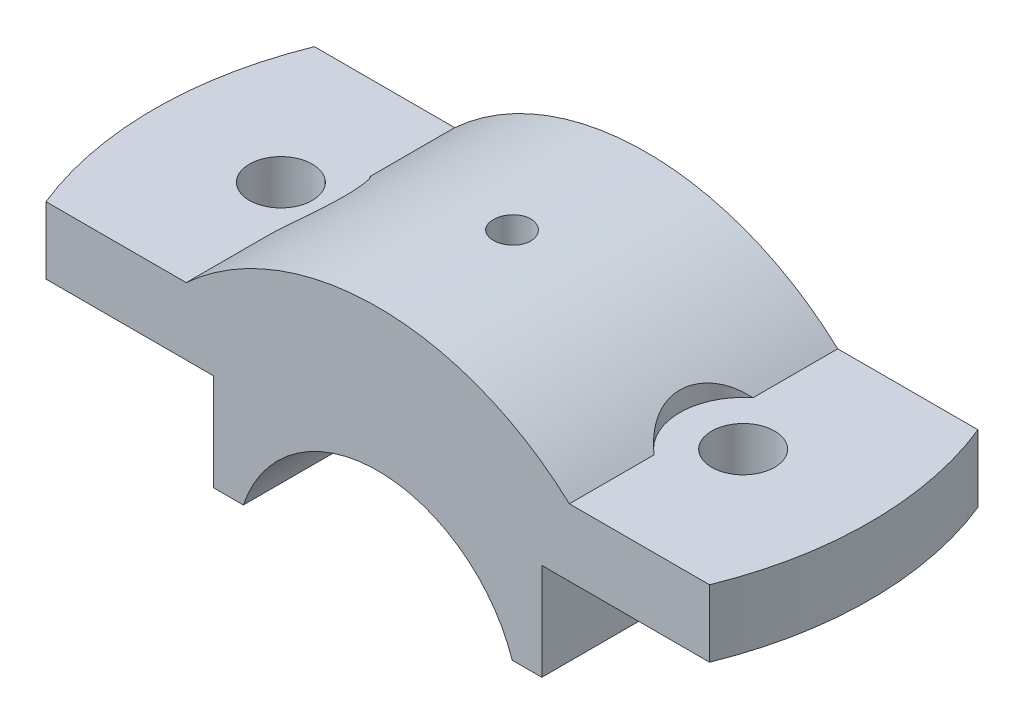
from build123d import *

# Parameters (mm, degrees)
BOSS_EXTRUDE1_DEPTH            = 18
CUT_EXTRUDE1_REACH             = 24
SKETCH2_R                      = 4.221723053
CUT_EXTRUDE1_DIRECTION_2_DEPTH = 11
SKETCH3_R                      = 8.5
CUT_EXTRUDE2_DEPTH             = 36
SKETCH18_W                     = 2.5
SKETCH18_H                     = 13
M5_TAPPED_HOLE1_D              = 4.2


with BuildPart() as part:
    # Sketch1 → Boss-Extrude1 (new body, symmetric)
    with BuildSketch(Plane.XY):
        with BuildLine():
            Line((18.027756377, 6), (22, 6))
            Line((22, 6), (22, 19))
            Line((22, 19), (49, 19))
            Line((49, 19), (49, 28))
            Line((49, 28), (25.690465157, 28))
            ThreePointArc((25.690465157, 28), (0, 38), (-25.690465157, 28))
            Line((-25.690465157, 28), (-49, 28))
            Line((-49, 28), (-49, 19))
            Line((-49, 19), (-22, 19))
            Line((-22, 19), (-22, 6))
            Line((-22, 6), (-18.027756377, 6))
            ThreePointArc((-18.027756377, 6), (0, 19), (18.027756377, 6))
        make_face()
    extrude(amount=BOSS_EXTRUDE1_DEPTH, both=True)

    # Sketch2 → Cut-Extrude1 (cut, up to next)
    with BuildSketch(Plane(origin=(0, 28, 0), x_dir=(1, 0, 0), z_dir=(0, 1, 0)), mode=Mode.PRIVATE) as cut_extrude1_sk1:
        with Locations((-31, 0)):
            Circle(SKETCH2_R)
    cut_extrude1_tool1 = extrude(cut_extrude1_sk1.sketch, amount=-CUT_EXTRUDE1_REACH, mode=Mode.PRIVATE) & part.part
    add(cut_extrude1_tool1.solids().sort_by_distance((-31, 28, 0))[0], mode=Mode.SUBTRACT)
    # Sketch2 → Cut-Extrude1 (cut, up to next)
    with BuildSketch(Plane(origin=(0, 28, 0), x_dir=(1, 0, 0), z_dir=(0, 1, 0)), mode=Mode.PRIVATE) as cut_extrude1_sk2:
        with Locations((31, 0)):
            Circle(SKETCH2_R)
    cut_extrude1_tool2 = extrude(cut_extrude1_sk2.sketch, amount=-CUT_EXTRUDE1_REACH, mode=Mode.PRIVATE) & part.part
    add(cut_extrude1_tool2.solids().sort_by_distance((31, 28, 0))[0], mode=Mode.SUBTRACT)
    # Sketch2 → Cut-Extrude1 (cut, up to next)
    with BuildSketch(Plane(origin=(0, 28, 0), x_dir=(1, 0, 0), z_dir=(0, 1, 0)), mode=Mode.PRIVATE) as cut_extrude1_sk3:
        with BuildLine():
            Line((-44.497190923, 18), (-49, 18))
            Line((-49, 18), (-49, -18))
            Line((-49, -18), (-44.497190923, -18))
            ThreePointArc((-44.497190923, -18), (-48, 0), (-44.497190923, 18))
        make_face()
    cut_extrude1_tool3 = extrude(cut_extrude1_sk3.sketch, amount=-CUT_EXTRUDE1_REACH, mode=Mode.PRIVATE) & part.part
    add(cut_extrude1_tool3.solids().sort_by_distance((-48.362805, 28, 0))[0], mode=Mode.SUBTRACT)
    # Sketch2 → Cut-Extrude1 (cut, up to next)
    with BuildSketch(Plane(origin=(0, 28, 0), x_dir=(1, 0, 0), z_dir=(0, 1, 0)), mode=Mode.PRIVATE) as cut_extrude1_sk4:
        with BuildLine():
            Line((44.497190923, -18), (49, -18))
            Line((49, -18), (49, 18))
            Line((49, 18), (44.497190923, 18))
            ThreePointArc((44.497190923, 18), (48, 0), (44.497190923, -18))
        make_face()
    cut_extrude1_tool4 = extrude(cut_extrude1_sk4.sketch, amount=-CUT_EXTRUDE1_REACH, mode=Mode.PRIVATE) & part.part
    add(cut_extrude1_tool4.solids().sort_by_distance((46.748595, 28, 17.637195))[0], mode=Mode.SUBTRACT)

    # Sketch2 → Cut-Extrude1 direction 2 (cut)
    with BuildSketch(Plane(origin=(0, 28, 0), x_dir=(1, 0, 0), z_dir=(0, 1, 0))):
        with Locations((-31, 0)):
            Circle(SKETCH2_R)
        with Locations((31, 0)):
            Circle(SKETCH2_R)
        with BuildLine():
            Line((-44.497190923, 18), (-49, 18))
            Line((-49, 18), (-49, -18))
            Line((-49, -18), (-44.497190923, -18))
            ThreePointArc((-44.497190923, -18), (-48, 0), (-44.497190923, 18))
        make_face()
        with BuildLine():
            Line((44.497190923, -18), (49, -18))
            Line((49, -18), (49, 18))
            Line((49, 18), (44.497190923, 18))
            ThreePointArc((44.497190923, 18), (48, 0), (44.497190923, -18))
        make_face()
    extrude(amount=CUT_EXTRUDE1_DIRECTION_2_DEPTH, mode=Mode.SUBTRACT)

    # Sketch3 → Cut-Extrude2 (cut)
    with BuildSketch(Plane(origin=(0, 28, 0), x_dir=(1, 0, 0), z_dir=(0, 1, 0))):
        with Locations((-31, 0)):
            Circle(SKETCH3_R)
        with Locations((31, 0)):
            Circle(SKETCH3_R)
    extrude(amount=CUT_EXTRUDE2_DEPTH, mode=Mode.SUBTRACT)

    # Sketch18 → M6 Tapped Hole2 (revolve, cut)
    with BuildSketch(Plane(origin=(0, 25, 0), x_dir=(0, 0, -1), z_dir=(1, 0, 0))):
        with Locations((1.25, 6.5)):
            Rectangle(SKETCH18_W, SKETCH18_H)
    revolve(axis=Axis((0, 18.65, 0), (0, 1, 0)), mode=Mode.SUBTRACT)

    # M5 Tapped Hole1 (through all)
    with Locations(Plane(origin=(0, 25, 0), x_dir=(1, 0, 0), z_dir=(0, 1, 0))):
        with Locations((0, 0)):
            Hole(M5_TAPPED_HOLE1_D / 2)


solid = part.part
